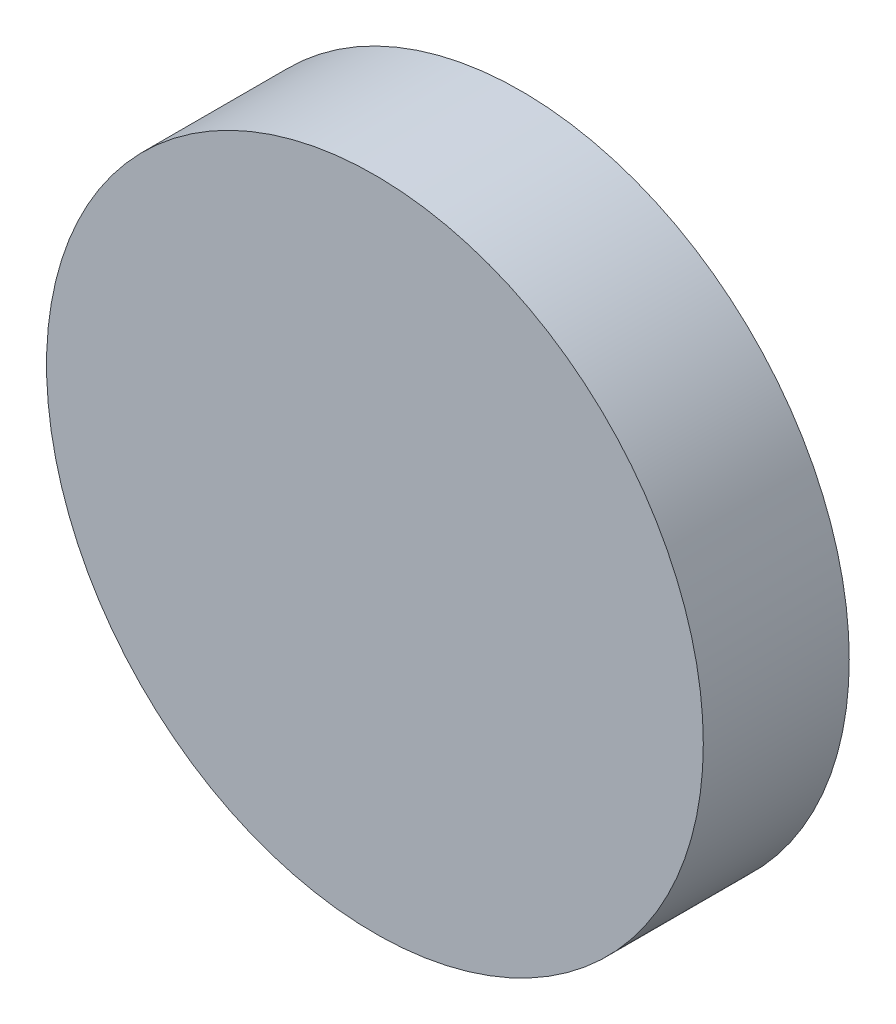
from build123d import *

# Parameters (mm, degrees)
SKETCH1_R           = 13.5
BOSS_EXTRUDE1_DEPTH = 6


with BuildPart() as part:
    # Sketch1 → Boss-Extrude1 (new body)
    with BuildSketch(Plane.XY):
        Circle(SKETCH1_R)
    extrude(amount=BOSS_EXTRUDE1_DEPTH)


solid = part.part
